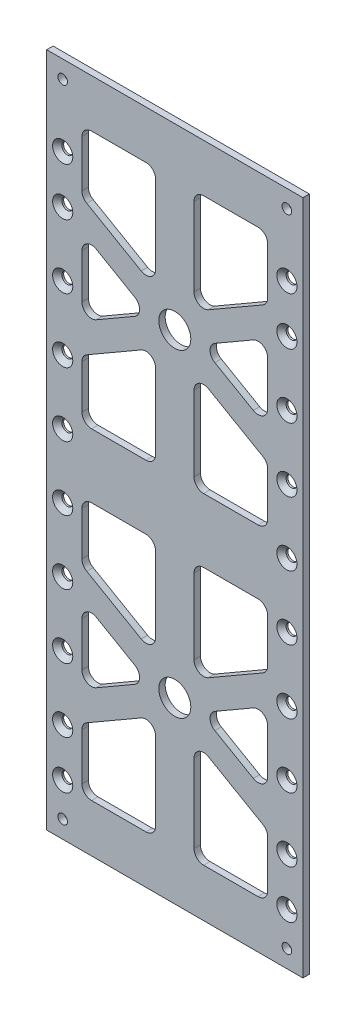
from build123d import *

# Parameters (mm, degrees)
SKETCH1_W                                       = 88
SKETCH1_H                                       = 211
BOSS_EXTRUDE1_DEPTH                             = 2
CUT_EXTRUDE2_DEPTH                              = 2
SKETCH4_R                                       = 5
CUT_EXTRUDE3_DEPTH                              = 3
FILLET2_R                                       = 3
SKETCH5_R                                       = 1.5
CUT_EXTRUDE4_DEPTH                              = 3
SKETCH23_W                                      = 2
SKETCH23_H                                      = 211
SKETCH23_W_2                                    = 2.150374681
CUT_EXTRUDE5_DEPTH                              = 10
SKETCH29_W                                      = 5.911493913
SKETCH29_H                                      = 211
SKETCH29_W_2                                    = 4.036537762
CUT_EXTRUDE10_DEPTH                             = 2
CSK_FOR_M3_FLAT_HEAD_MACHINE_SCREW1_D           = 3.4
CSK_FOR_M3_FLAT_HEAD_MACHINE_SCREW1_DEPTH       = 10
CSK_FOR_M3_FLAT_HEAD_MACHINE_SCREW1_CSINK_D     = 6.3
CSK_FOR_M3_FLAT_HEAD_MACHINE_SCREW1_CSINK_ANGLE = 90
CSK_FOR_M3_FLAT_HEAD_MACHINE_SCREW1_TIP         = 1.021463052


with BuildPart() as part:
    # Sketch1 → Boss-Extrude1 (new body)
    with BuildSketch(Plane.XY):
        with Locations((44, 105.5)):
            Rectangle(SKETCH1_W, SKETCH1_H)
    extrude(amount=BOSS_EXTRUDE1_DEPTH)

    # Sketch3 → Cut-Extrude2 (cut)
    with BuildSketch(Plane.XY.offset(2)):
        Polygon((73, 133.88804004), (50, 147.167096231), (50, 115.5), (73, 115.5), align=None)
        Polygon((38, 115.5), (38, 147.167096231), (15, 133.88804004), (15, 115.5), align=None)
        Polygon((15, 143.125644347), (36, 155.25), (15, 167.374355653), align=None)
        Polygon((73, 143.125644347), (73, 167.374355653), (52, 155.25), align=None)
        Polygon((73, 196), (50, 196), (50, 163.332903769), (73, 176.61195996), align=None)
        Polygon((38, 163.332903769), (38, 196), (15, 196), (15, 176.61195996), align=None)
    cut_extrude2 = extrude(amount=-CUT_EXTRUDE2_DEPTH, mode=Mode.SUBTRACT)

    # Sketch4 → Cut-Extrude3 (cut, through all)
    with BuildSketch(Plane.XY.offset(2)):
        with Locations((44, 155.25)):
            Circle(SKETCH4_R)
    cut_extrude3 = extrude(amount=-CUT_EXTRUDE3_DEPTH, mode=Mode.SUBTRACT)

    # Mirror2: Cut-Extrude2, Cut-Extrude3 across plane
    add(cut_extrude2.mirror(Plane.ZX.offset(105.5)), mode=Mode.SUBTRACT)
    add(cut_extrude3.mirror(Plane.ZX.offset(105.5)), mode=Mode.SUBTRACT)

    # Fillet2
    fillet2_edges = [part.edges().sort_by_distance(p)[0] for p in [
        (36, 55.75, 1),
        (15, 43.625644347, 1),
        (15, 67.874355653, 1),
        (38, 95.5, 1),
        (38, 63.832903769, 1),
        (15, 77.11195996, 1),
        (15, 95.5, 1),
        (73, 15, 1),
        (50, 15, 1),
        (50, 47.667096231, 1),
        (73, 34.38804004, 1),
        (73, 43.625644347, 1),
        (52, 55.75, 1),
        (73, 67.874355653, 1),
        (15, 15, 1),
        (15, 34.38804004, 1),
        (38, 47.667096231, 1),
        (38, 15, 1),
        (73, 77.11195996, 1),
        (50, 63.832903769, 1),
        (50, 95.5, 1),
        (73, 95.5, 1),
        (15, 167.374355653, 1),
        (36, 155.25, 1),
        (15, 143.125644347, 1),
        (38, 147.167096231, 1),
        (38, 115.5, 1),
        (15, 115.5, 1),
        (15, 133.88804004, 1),
        (50, 196, 1),
        (73, 196, 1),
        (73, 176.61195996, 1),
        (50, 163.332903769, 1),
        (52, 155.25, 1),
        (73, 167.374355653, 1),
        (73, 143.125644347, 1),
        (15, 176.61195996, 1),
        (15, 196, 1),
        (38, 196, 1),
        (38, 163.332903769, 1),
        (50, 147.167096231, 1),
        (73, 133.88804004, 1),
        (73, 115.5, 1),
        (50, 115.5, 1),
    ]]
    fillet(fillet2_edges, radius=FILLET2_R)

    # Sketch5 → Cut-Extrude4 (cut, through all)
    with BuildSketch(Plane.XY.offset(2)):
        with Locations((9, 205.5)):
            Circle(SKETCH5_R)
        with Locations((79, 205.5)):
            Circle(SKETCH5_R)
        with Locations((9, 5.5)):
            Circle(SKETCH5_R)
        with Locations((79, 5.5)):
            Circle(SKETCH5_R)
    extrude(amount=-CUT_EXTRUDE4_DEPTH, mode=Mode.SUBTRACT)

    # Sketch23 → Cut-Extrude5 (cut)
    with BuildSketch(Plane.XY.offset(2)):
        with Locations((87, 105.5)):
            Rectangle(SKETCH23_W, SKETCH23_H)
        with Locations((1.075187341, 105.5)):
            Rectangle(SKETCH23_W_2, SKETCH23_H)
    extrude(amount=-CUT_EXTRUDE5_DEPTH, mode=Mode.SUBTRACT)

    # Sketch29 → Cut-Extrude10 (cut)
    with BuildSketch(Plane(origin=(0, 0, 0), x_dir=(-1, 0, 0), z_dir=(0, 0, -1))):
        with Locations((-1.044253043, 105.5)):
            Rectangle(SKETCH29_W, SKETCH29_H)
        with Locations((-86.018268881, 105.5)):
            Rectangle(SKETCH29_W_2, SKETCH29_H)
    extrude(amount=-CUT_EXTRUDE10_DEPTH, mode=Mode.SUBTRACT)

    # CSK for M3 Flat Head Machine Screw1
    with Locations(Plane.XY.offset(2)):
        with Locations((9, 186), (9, 171), (9, 151), (9, 131), (9, 111), (9, 91), (9, 71), (9, 51), (9, 31), (9, 16), (79, 186), (79, 171), (79, 151), (79, 131), (79, 111), (79, 91), (79, 71), (79, 51), (79, 31), (79, 16)):
            CounterSinkHole(CSK_FOR_M3_FLAT_HEAD_MACHINE_SCREW1_D / 2, CSK_FOR_M3_FLAT_HEAD_MACHINE_SCREW1_CSINK_D / 2, depth=CSK_FOR_M3_FLAT_HEAD_MACHINE_SCREW1_DEPTH, counter_sink_angle=CSK_FOR_M3_FLAT_HEAD_MACHINE_SCREW1_CSINK_ANGLE)
            with Locations((0, 0, -(CSK_FOR_M3_FLAT_HEAD_MACHINE_SCREW1_DEPTH + CSK_FOR_M3_FLAT_HEAD_MACHINE_SCREW1_TIP / 2))):  # 118° drill point
                Cone(0, CSK_FOR_M3_FLAT_HEAD_MACHINE_SCREW1_D / 2, CSK_FOR_M3_FLAT_HEAD_MACHINE_SCREW1_TIP, mode=Mode.SUBTRACT)


solid = part.part
